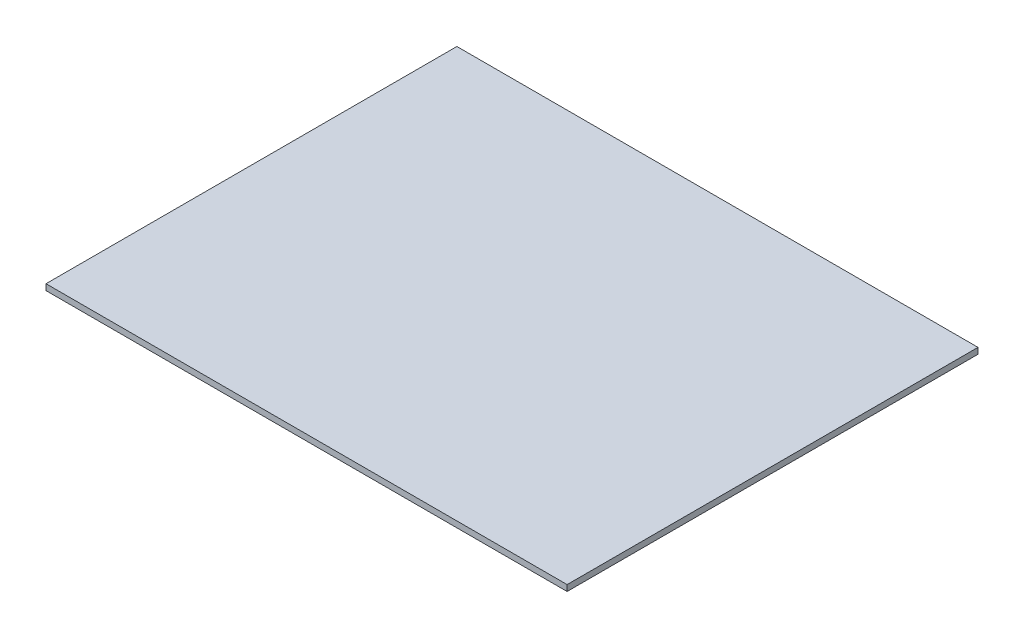
from build123d import *

# Parameters (mm, degrees)
SKETCH1_W           = 260
SKETCH1_H           = 205
BOSS_EXTRUDE1_DEPTH = 3


with BuildPart() as part:
    # Sketch1 → Boss-Extrude1 (new body)
    with BuildSketch(Plane(origin=(0, 0, 0), x_dir=(1, 0, 0), z_dir=(0, 1, 0))):
        with Locations((-11.284722222, -24.635416667)):
            Rectangle(SKETCH1_W, SKETCH1_H)
    extrude(amount=BOSS_EXTRUDE1_DEPTH)


solid = part.part
